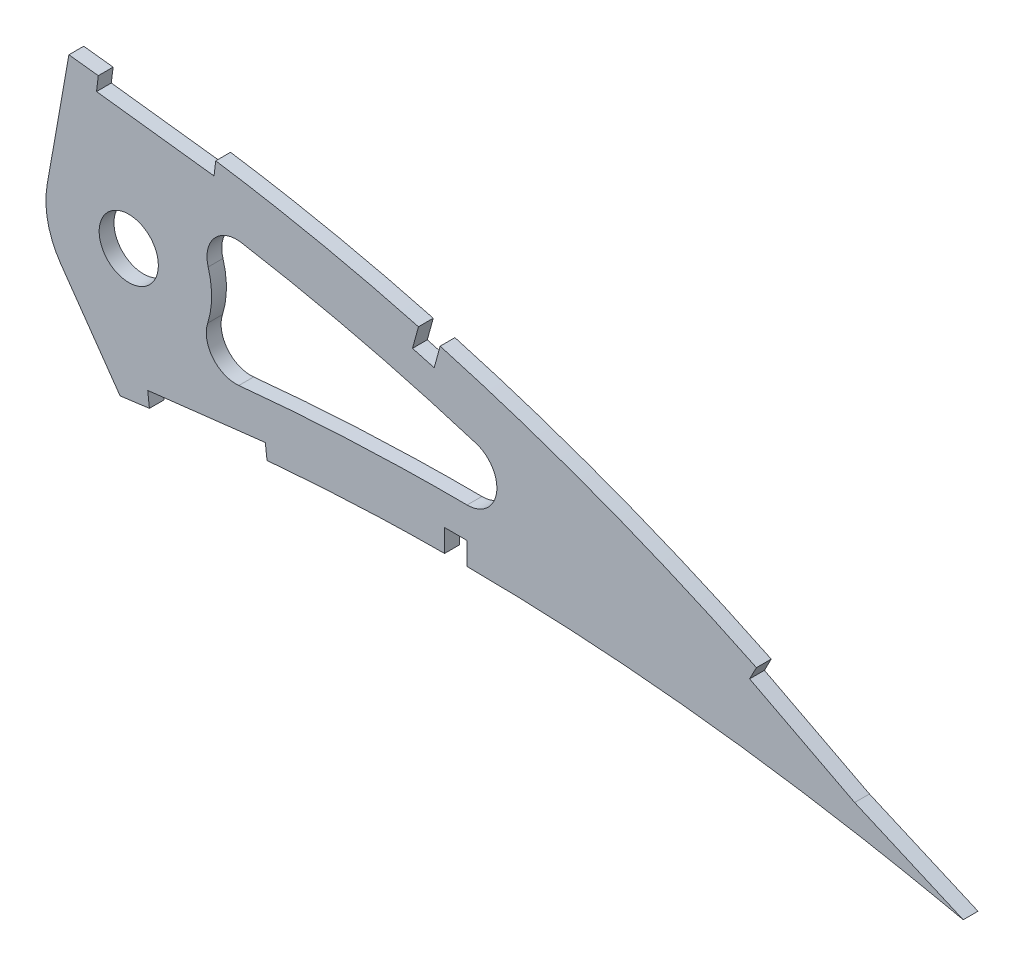
from build123d import *

# Parameters (mm, degrees)
BOSS_EXTRUDE1_DEPTH = 3.175
SKETCH2_R           = 6.35
CUT_EXTRUDE2_DEPTH  = 564.352625878
CUT_EXTRUDE3_DEPTH  = 5.08
FILLET1_R           = 6.35


with BuildPart() as part:
    # Sketch1 → Boss-Extrude1 (new body)
    with BuildSketch(Plane.XY):
        with BuildLine():
            Line((554.319679776, 0.86419944), (558.957809165, -2.001035064))
            Line((558.957809165, -2.001035064), (553.628320224, -0.86419944))
            add(Edge.make_bspline(
                [(0, 0), (0.142347333, -0.671974339), (0.427696201, -2.019011291), (1.202951825, -3.958186399), (2.228190383, -5.822295383), (3.524929277, -7.606386734), (5.084546434, -9.309972854), (6.903597265, -10.934825666), (8.980297835, -12.480071531), (11.311930113, -13.945007192), (13.895107055, -15.331187734), (16.726925172, -16.637751335), (19.804802415, -17.864289685), (23.125385358, -19.009163213), (26.684614497, -20.074115536), (30.479105895, -21.056551439), (34.504544841, -21.957844058), (38.757059621, -22.775692741), (43.232016315, -23.51092839), (47.924766072, -24.163139529), (52.830492114, -24.732734078), (57.944381557, -25.218516849), (63.261376247, -25.621532707), (68.776176668, -25.942049027), (74.483429701, -26.181082136), (80.377668399, -26.337723359), (86.453120028, -26.414414727), (92.704294081, -26.412307583), (99.12507542, -26.330838336), (105.709979181, -26.174507632), (112.452686417, -25.942325241), (119.34710982, -25.637100851), (126.387030529, -25.261906112), (133.566134503, -24.818012975), (140.878103886, -24.307388732), (148.316589874, -23.734128332), (155.874835295, -23.099661672), (163.546248351, -22.407686904), (171.324037493, -21.661668186), (179.201482843, -20.863966544), (187.171631155, -20.018334408), (195.227383554, -19.127512044), (203.361887075, -18.196251983), (211.567710876, -17.226239107), (219.837916048, -16.22301178), (228.164722411, -15.188486752), (236.541167073, -14.126648704), (244.959716224, -13.042497308), (253.412488668, -11.935908902), (261.892375024, -10.814767477), (270.391197565, -9.678149682), (278.901558654, -8.531901132), (287.415580323, -7.379584718), (295.924969849, -6.221555103), (304.422247183, -5.062611436), (312.899529628, -3.905935256), (321.348513524, -2.751632242), (329.761554776, -1.605439772), (338.130181703, -0.467217682), (346.446677596, 0.66072628), (354.703072912, 1.775025333), (362.891578136, 2.874273125), (371.003746299, 3.95777416), (379.031415912, 5.025935363), (386.846329345, 6.046335331), (394.428066205, 7.073310729), (401.802175451, 7.915202937), (409.084467689, 8.633788237), (416.282507375, 9.222929029), (423.387651297, 9.691101248), (430.391758492, 10.041650224), (437.286481508, 10.279470026), (444.063111322, 10.411615906), (450.713183761, 10.441441391), (457.227621753, 10.378458054), (463.597952606, 10.227742854), (469.815285453, 9.996060674), (475.870946567, 9.691228076), (481.756334452, 9.321555013), (487.462613384, 8.892494437), (492.981831848, 8.414063018), (498.305474549, 7.893264408), (503.42536692, 7.336048865), (508.334038343, 6.754092224), (513.023631908, 6.151226115), (517.487093749, 5.537357776), (521.717238913, 4.918708145), (525.707368004, 4.303175514), (529.451211936, 3.69663199), (532.942723228, 3.107128036), (536.176432542, 2.540171416), (539.146728498, 2.001298937), (541.849490456, 1.497309641), (544.279380439, 1.030707122), (546.433148645, 0.609181062), (548.306790372, 0.234591467), (549.897558991, -0.087784135), (551.202676422, -0.356673457), (552.220160436, -0.56766247), (552.948001318, -0.721088328), (553.38541182, -0.812384542), (553.579758931, -0.853840809), (553.628320224, -0.86419944)],
                knots=[0, 0, 0, 0, 0.003638255, 0.007293231, 0.011028136, 0.014901081, 0.018963272, 0.023258475, 0.027820626, 0.032679082, 0.03785316, 0.043361875, 0.049214679, 0.055422346, 0.061988786, 0.068918036, 0.076211157, 0.083868392, 0.091887411, 0.100265912, 0.108999867, 0.118084529, 0.127514843, 0.13728527, 0.147387917, 0.157816481, 0.168563473, 0.179619128, 0.190977373, 0.202626974, 0.214560478, 0.226767249, 0.239236417, 0.251959004, 0.264923894, 0.278119703, 0.291536035, 0.30516028, 0.318980685, 0.332985499, 0.34716279, 0.361498603, 0.375980747, 0.390597192, 0.405332593, 0.420174823, 0.435109533, 0.450124276, 0.465203068, 0.480333154, 0.495500583, 0.510689775, 0.525887334, 0.541078314, 0.556247233, 0.571381784, 0.58646604, 0.601484516, 0.616424329, 0.631269422, 0.646006524, 0.660620684, 0.675098187, 0.689422858, 0.703581825, 0.716907563, 0.730009274, 0.742952128, 0.755725558, 0.768319952, 0.780724337, 0.792926529, 0.804916041, 0.816679084, 0.828203524, 0.8394749, 0.850481359, 0.861207697, 0.871639326, 0.881763414, 0.891563605, 0.901027364, 0.910138977, 0.918883976, 0.927249278, 0.935221104, 0.942784739, 0.949928188, 0.956638464, 0.962904203, 0.968712288, 0.974054485, 0.978918432, 0.983297218, 0.987180246, 0.990560674, 0.993433357, 0.995790626, 0.997629587, 0.998945816, 0.999736592, 1, 1, 1, 1], degree=3))
            add(Edge.make_bspline(
                [(554.319679776, 0.86419944), (554.277215357, 0.89043211), (554.107522459, 0.995260998), (553.725173452, 1.229788681), (553.088482836, 1.620406322), (552.19717161, 2.164400829), (551.051931791, 2.860327436), (549.65218736, 3.7033132), (547.998812126, 4.690619378), (546.092206237, 5.81757636), (543.932565, 7.078907467), (541.52071076, 8.469502775), (538.856853433, 9.981489509), (535.942024994, 11.608689713), (532.777225355, 13.343364367), (529.363053286, 15.177678879), (525.700731311, 17.102302694), (521.79166531, 19.108957931), (517.636567952, 21.18656326), (513.237398289, 23.326472309), (508.595621965, 25.518015349), (503.712823317, 27.749500198), (498.591807417, 30.011830061), (493.233990123, 32.290940283), (487.642424763, 34.57695634), (481.8194918, 36.856868062), (475.768638934, 39.12029206), (469.492200651, 41.35256543), (462.994868721, 43.543932934), (456.279795024, 45.680158729), (449.351781723, 47.749641178), (442.214854104, 49.738962731), (434.874961581, 51.637921), (427.336759134, 53.432686996), (419.606635925, 55.111247293), (411.690736529, 56.663495899), (403.59569977, 58.073935714), (395.343957759, 59.341467114), (387.068279135, 60.395838633), (378.809627081, 61.42993544), (370.563274167, 62.401374837), (362.216133558, 63.331662392), (353.776235693, 64.21556045), (345.251952273, 65.05030505), (336.651912889, 65.832293537), (327.985054567, 66.559232675), (319.259763743, 67.227003304), (310.485240764, 67.834576684), (301.670160415, 68.37661144), (292.823911811, 68.852700647), (283.955475072, 69.25952388), (275.074079257, 69.594278035), (266.18915515, 69.854942273), (257.309925599, 70.039019354), (248.446004557, 70.145351939), (239.606611877, 70.171034575), (230.801357025, 70.115607817), (222.039460543, 69.97716855), (213.3305417, 69.753821594), (204.683833617, 69.445150093), (196.108686361, 69.051287938), (187.614488849, 68.568936811), (179.210455771, 68.001170586), (170.905945703, 67.345604232), (162.710082946, 66.602063396), (154.631456842, 65.773647434), (146.679061666, 64.85810318), (138.86141998, 63.858035618), (131.187082706, 62.775405546), (123.664660665, 61.60962319), (116.302212041, 60.364055914), (109.107683022, 59.039978082), (102.088685401, 57.641271481), (95.252861003, 56.16830103), (88.607445909, 54.6254852), (82.159346438, 53.015511993), (75.915494147, 51.341328746), (69.8822185, 49.606952764), (64.065620452, 47.816318831), (58.472480769, 45.971394518), (53.107026632, 44.079174913), (47.975848961, 42.141003285), (43.082878389, 40.162850581), (38.433849103, 38.1474178), (34.032234114, 36.100849009), (29.88301504, 34.025474172), (25.989149052, 31.927107779), (22.354545271, 29.808967438), (18.982702419, 27.674987384), (15.875037644, 25.530580581), (13.035835571, 23.377093004), (10.466071509, 21.219966433), (8.16737168, 19.062485607), (6.143021854, 16.906136722), (4.392949166, 14.754717117), (2.919447156, 12.609930647), (1.722771461, 10.473806788), (0.805628768, 8.347897258), (0.167109617, 6.233397613), (-0.182411483, 4.133428796), (-0.269409401, 2.046307302), (-0.089668952, 0.681083253), (0, 0)],
                knots=[0, 0, 0, 0, 0.00025409, 0.001015373, 0.002283359, 0.004056577, 0.006330982, 0.009105274, 0.012374489, 0.016134023, 0.02037966, 0.025105976, 0.030306237, 0.035972206, 0.042099522, 0.048678064, 0.055701664, 0.063160184, 0.071045824, 0.079349827, 0.08806291, 0.097175756, 0.106678112, 0.116561573, 0.126814276, 0.137428301, 0.148393618, 0.15969976, 0.171338126, 0.183297699, 0.195569604, 0.208143555, 0.221011593, 0.234161831, 0.24758745, 0.261276822, 0.27522271, 0.289414144, 0.3037712, 0.317689227, 0.331784111, 0.346039677, 0.360443869, 0.37498272, 0.389640454, 0.404403317, 0.419256601, 0.434186749, 0.449177265, 0.464214782, 0.479284009, 0.49436974, 0.509457833, 0.524532346, 0.53957932, 0.554582984, 0.569529546, 0.584403417, 0.599190992, 0.613876838, 0.628447475, 0.642888675, 0.657186054, 0.671325546, 0.685294014, 0.699078147, 0.712665095, 0.726042645, 0.739197713, 0.752117586, 0.764792042, 0.777208152, 0.789355685, 0.80122396, 0.812803686, 0.824082909, 0.835054602, 0.845709571, 0.856037853, 0.866033834, 0.875688843, 0.884997719, 0.893953426, 0.902552897, 0.910789386, 0.918660734, 0.926166253, 0.933302626, 0.94007122, 0.94647478, 0.952517526, 0.958204819, 0.963546652, 0.9685566, 0.973249913, 0.977651041, 0.981787043, 0.985694226, 0.989415109, 0.993001157, 0.996508416, 1, 1, 1, 1], degree=3))
        make_face()
    extrude(amount=BOSS_EXTRUDE1_DEPTH)

    # Sketch2 → Cut-Extrude2 (cut, through all)
    with BuildSketch(Plane.XY.offset(3.175)):
        with BuildLine():
            ThreePointArc((365.353734087, 23.034385848), (362.559714427, 29.38427855), (362.408375585, 36.320039485))
            Line((362.408375585, 36.320039485), (367.075336078, 62.787687681))
            add(Edge.make_bspline(
                [(367.075336078, 62.787687681), (365.465275325, 62.967891991), (361.042274284, 63.454598943), (353.776235693, 64.21556045), (345.251952273, 65.05030505), (336.651912889, 65.832293537), (327.985054567, 66.559232675), (319.259763743, 67.227003304), (310.485240764, 67.834576684), (301.670160415, 68.37661144), (292.823911811, 68.852700647), (283.955475072, 69.25952388), (275.074079257, 69.594278035), (266.18915515, 69.854942273), (257.309925599, 70.039019354), (248.446004557, 70.145351939), (239.606611877, 70.171034575), (230.801357025, 70.115607817), (222.039460543, 69.97716855), (213.3305417, 69.753821594), (204.683833617, 69.445150093), (196.108686361, 69.051287938), (187.614488849, 68.568936811), (179.210455771, 68.001170586), (170.905945703, 67.345604232), (162.710082946, 66.602063396), (154.631456842, 65.773647434), (146.679061666, 64.85810318), (138.86141998, 63.858035618), (131.187082706, 62.775405546), (123.664660665, 61.60962319), (116.302212041, 60.364055914), (109.107683022, 59.039978082), (102.088685401, 57.641271481), (95.252861003, 56.16830103), (88.607445909, 54.6254852), (82.159346438, 53.015511993), (75.915494147, 51.341328746), (69.8822185, 49.606952764), (64.065620452, 47.816318831), (58.472480769, 45.971394518), (53.107026632, 44.079174913), (47.975848961, 42.141003285), (43.082878389, 40.162850581), (38.433849103, 38.1474178), (34.032234114, 36.100849009), (29.88301504, 34.025474172), (25.989149052, 31.927107779), (22.354545271, 29.808967438), (18.982702419, 27.674987384), (15.875037644, 25.530580581), (13.035835571, 23.377093004), (10.466071509, 21.219966433), (8.16737168, 19.062485607), (6.143021854, 16.906136722), (4.392949166, 14.754717117), (2.919447156, 12.609930647), (1.722771461, 10.473806788), (0.805628768, 8.347897258), (0.167109617, 6.233397613), (-0.182411483, 4.133428796), (-0.269409401, 2.046307302), (-0.089668952, 0.681083253), (0, 0)],
                knots=[0.33779237, 0.33779237, 0.33779237, 0.33779237, 0.346039677, 0.360443869, 0.37498272, 0.389640454, 0.404403317, 0.419256601, 0.434186749, 0.449177265, 0.464214782, 0.479284009, 0.49436974, 0.509457833, 0.524532346, 0.53957932, 0.554582984, 0.569529546, 0.584403417, 0.599190992, 0.613876838, 0.628447475, 0.642888675, 0.657186054, 0.671325546, 0.685294014, 0.699078147, 0.712665095, 0.726042645, 0.739197713, 0.752117586, 0.764792042, 0.777208152, 0.789355685, 0.80122396, 0.812803686, 0.824082909, 0.835054602, 0.845709571, 0.856037853, 0.866033834, 0.875688843, 0.884997719, 0.893953426, 0.902552897, 0.910789386, 0.918660734, 0.926166253, 0.933302626, 0.94007122, 0.94647478, 0.952517526, 0.958204819, 0.963546652, 0.9685566, 0.973249913, 0.977651041, 0.981787043, 0.985694226, 0.989415109, 0.993001157, 0.996508416, 1, 1, 1, 1], degree=3))
            add(Edge.make_bspline(
                [(0, 0), (0.142347333, -0.671974339), (0.427696201, -2.019011291), (1.202951825, -3.958186399), (2.228190383, -5.822295383), (3.524929277, -7.606386734), (5.084546434, -9.309972854), (6.903597265, -10.934825666), (8.980297835, -12.480071531), (11.311930113, -13.945007192), (13.895107055, -15.331187734), (16.726925172, -16.637751335), (19.804802415, -17.864289685), (23.125385358, -19.009163213), (26.684614497, -20.074115536), (30.479105895, -21.056551439), (34.504544841, -21.957844058), (38.757059621, -22.775692741), (43.232016315, -23.51092839), (47.924766072, -24.163139529), (52.830492114, -24.732734078), (57.944381557, -25.218516849), (63.261376247, -25.621532707), (68.776176668, -25.942049027), (74.483429701, -26.181082136), (80.377668399, -26.337723359), (86.453120028, -26.414414727), (92.704294081, -26.412307583), (99.12507542, -26.330838336), (105.709979181, -26.174507632), (112.452686417, -25.942325241), (119.34710982, -25.637100851), (126.387030529, -25.261906112), (133.566134503, -24.818012975), (140.878103886, -24.307388732), (148.316589874, -23.734128332), (155.874835295, -23.099661672), (163.546248351, -22.407686904), (171.324037493, -21.661668186), (179.201482843, -20.863966544), (187.171631155, -20.018334408), (195.227383554, -19.127512044), (203.361887075, -18.196251983), (211.567710876, -17.226239107), (219.837916048, -16.22301178), (228.164722411, -15.188486752), (236.541167073, -14.126648704), (244.959716224, -13.042497308), (253.412488668, -11.935908902), (261.892375024, -10.814767477), (270.391197565, -9.678149682), (278.901558654, -8.531901132), (287.415580323, -7.379584718), (295.924969849, -6.221555103), (304.422247183, -5.062611436), (312.899529628, -3.905935256), (321.348513524, -2.751632242), (329.761554776, -1.605439772), (338.130181703, -0.467217682), (346.446677596, 0.66072628), (354.703072912, 1.775025333), (362.891578136, 2.874273125), (370.668165364, 3.912952321), (375.714480947, 4.584573642), (378.055850936, 4.893882987)],
                knots=[0, 0, 0, 0, 0.003638255, 0.007293231, 0.011028136, 0.014901081, 0.018963272, 0.023258475, 0.027820626, 0.032679082, 0.03785316, 0.043361875, 0.049214679, 0.055422346, 0.061988786, 0.068918036, 0.076211157, 0.083868392, 0.091887411, 0.100265912, 0.108999867, 0.118084529, 0.127514843, 0.13728527, 0.147387917, 0.157816481, 0.168563473, 0.179619128, 0.190977373, 0.202626974, 0.214560478, 0.226767249, 0.239236417, 0.251959004, 0.264923894, 0.278119703, 0.291536035, 0.30516028, 0.318980685, 0.332985499, 0.34716279, 0.361498603, 0.375980747, 0.390597192, 0.405332593, 0.420174823, 0.435109533, 0.450124276, 0.465203068, 0.480333154, 0.495500583, 0.510689775, 0.525887334, 0.541078314, 0.556247233, 0.571381784, 0.58646604, 0.601484516, 0.616424329, 0.631269422, 0.646006524, 0.660620684, 0.675098187, 0.687626828, 0.687626828, 0.687626828, 0.687626828], degree=3))
            Line((378.055850936, 4.893882987), (365.353734087, 23.034385848))
        make_face()
        with BuildLine():
            add(Edge.make_bspline(
                [(493.241235329, 19.857936242), (490.333445909, 21.111002828), (476.399340837, 26.924853631), (456.52960869, 33.93583905), (433.559916556, 40.30104796), (419.0319559, 43.611182504), (407.346649337, 45.84098905), (398.505154033, 47.324243908), (392.367430705, 48.18322455), (389.071118771, 48.616014811), (388.763678671, 48.656158229)],
                knots=[0.108324424, 0.108324424, 0.108324424, 0.108324424, 0.124893292, 0.187339938, 0.218563261, 0.249786584, 0.265398246, 0.281009907, 0.296621569, 0.298224055, 0.298224055, 0.298224055, 0.298224055], degree=3))
            ThreePointArc((388.763678671, 48.656158229), (397.698213714, 33.272004402), (388.831999198, 17.848374947))
            add(Edge.make_bspline(
                [(388.831999198, 17.848374947), (389.146533539, 17.890053591), (390.938425173, 18.126637921), (394.271002649, 18.553749964), (398.782386561, 19.07312417), (404.770940057, 19.70534233), (415.30220739, 20.663357736), (430.359885785, 21.580543142), (454.500376677, 22.103876727), (475.479215147, 21.339969589), (490.36570835, 20.118810716), (493.241235329, 19.857936242)],
                knots=[0.709526905, 0.709526905, 0.709526905, 0.709526905, 0.711194511, 0.719000065, 0.726805619, 0.734611173, 0.75022228, 0.781444495, 0.81266671, 0.87511114, 0.890078926, 0.890078926, 0.890078926, 0.890078926], degree=3))
        make_face()
        with Locations((379.918257434, 33.232574886)):
            Circle(SKETCH2_R)
    extrude(amount=-CUT_EXTRUDE2_DEPTH, mode=Mode.SUBTRACT)

    # Sketch3 → Cut-Extrude3 (cut)
    with BuildSketch(Plane.XY.offset(3.175)):
        Polygon((373.384209081, 62.066146752), (398.597413422, 58.991357842), (398.213064809, 55.839707299), (372.999860467, 58.914496209), align=None)
        Polygon((442.076553422, 49.751937681), (446.730089213, 48.473313171), (445.451464703, 43.819777379), (440.797928911, 45.09840189), align=None)
        Polygon((383.984612399, 8.876160583), (409.214400255, 11.811770357), (409.581351477, 8.658046875), (384.351563621, 5.722437101), align=None)
        Polygon((447.687263022, 15.249747444), (452.513259401, 15.243835899), (452.507347856, 10.41783952), (447.681351477, 10.423751065), align=None)
        Polygon((514.591609472, 22.66382608), (537.037169923, 11.007851459), (560.2254601, 0.90992459), (558.957809165, -2.001035064), (535.670131931, 8.14017241), (513.128367827, 19.846105567), align=None)
    extrude(amount=-CUT_EXTRUDE3_DEPTH, mode=Mode.SUBTRACT)


with BuildPart() as body_2:
    # of the pieces the cut leaves, the one that is kept (cut_extrude3_keep)
    add(part.part.solids().sort_by_distance((558.957809165, -2.001035064, 0))[0])

    # Fillet1
    fillet1_edges = [body_2.edges().sort_by_distance(p)[0] for p in [
        (493.241235329, 19.857936242, 1.5875),
        (388.831999198, 17.848374947, 1.5875),
        (388.763678671, 48.656158229, 1.5875),
    ]]
    fillet(fillet1_edges, radius=FILLET1_R)


solid = body_2.part
